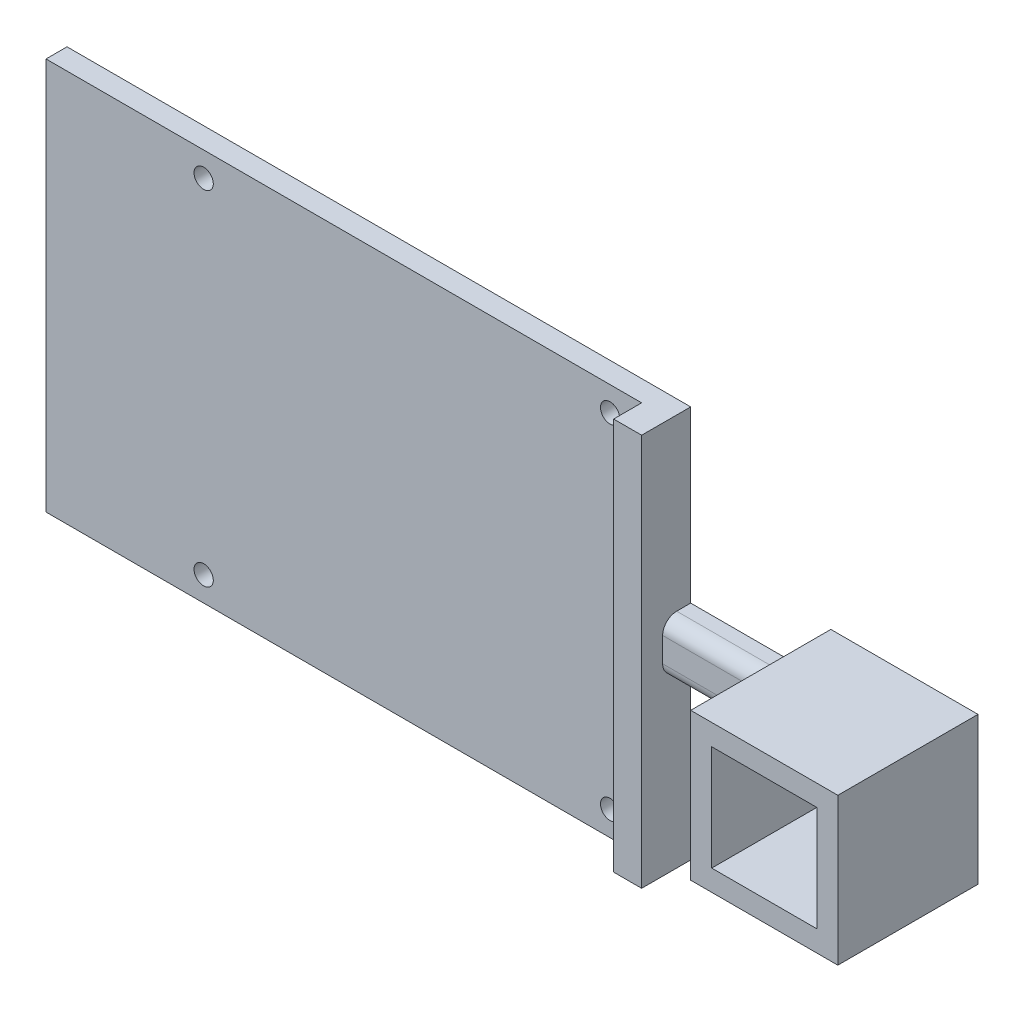
from build123d import *

# Parameters (mm, degrees)
SKETCH2_W           = 21
SKETCH2_H           = 21
BOSS_EXTRUDE1_DEPTH = 20
SKETCH3_W           = 15
SKETCH3_H           = 15
CUT_EXTRUDE1_DEPTH  = 20
SKETCH4_W           = 4
SKETCH4_H           = 7.5
BOSS_EXTRUDE2_DEPTH = 20
FILLET2_R           = 2
SKETCH5_W           = 7
SKETCH5_H           = 56
BOSS_EXTRUDE3_DEPTH = 4
SKETCH6_W           = 3
SKETCH6_H           = 56
BOSS_EXTRUDE4_DEPTH = 85
SKETCH8_R           = 1.375
CUT_EXTRUDE2_DEPTH  = 4


with BuildPart() as part:
    # Sketch2 → Boss-Extrude1 (new body)
    with BuildSketch(Plane.XY):
        Rectangle(SKETCH2_W, SKETCH2_H)
    extrude(amount=BOSS_EXTRUDE1_DEPTH)

    # Sketch3 → Cut-Extrude1 (cut)
    with BuildSketch(Plane.XY.offset(20)):
        Rectangle(SKETCH3_W, SKETCH3_H)
    extrude(amount=-CUT_EXTRUDE1_DEPTH, mode=Mode.SUBTRACT)

    # Sketch4 → Boss-Extrude2 (add)
    with BuildSketch(Plane.ZY.offset(10.5)):
        with Locations((2, 0)):
            Rectangle(SKETCH4_W, SKETCH4_H)
    extrude(amount=BOSS_EXTRUDE2_DEPTH)

    # Fillet2
    fillet2_edges = [part.edges().sort_by_distance(p)[0] for p in [
        (-20.5, -3.75, 4),
        (-20.5, 3.75, 4),
    ]]
    fillet(fillet2_edges, radius=FILLET2_R)

    # Sketch5 → Boss-Extrude3 (add)
    with BuildSketch(Plane.ZY.offset(30.5)):
        with Locations((3.5, 0)):
            Rectangle(SKETCH5_W, SKETCH5_H)
    extrude(amount=BOSS_EXTRUDE3_DEPTH)

    # Sketch6 → Boss-Extrude4 (add)
    with BuildSketch(Plane.ZY.offset(34.5)):
        with Locations((1.5, 0)):
            Rectangle(SKETCH6_W, SKETCH6_H)
    extrude(amount=BOSS_EXTRUDE4_DEPTH)

    # Sketch8 → Cut-Extrude2 (cut)
    with BuildSketch(Plane.XY.offset(3)):
        with Locations((-39, -24.5)):
            Circle(SKETCH8_R)
        with Locations((-39, 24.5)):
            Circle(SKETCH8_R)
        with Locations((-97, -24.5)):
            Circle(SKETCH8_R)
        with Locations((-97, 24.5)):
            Circle(SKETCH8_R)
    extrude(amount=-CUT_EXTRUDE2_DEPTH, mode=Mode.SUBTRACT)


solid = part.part
